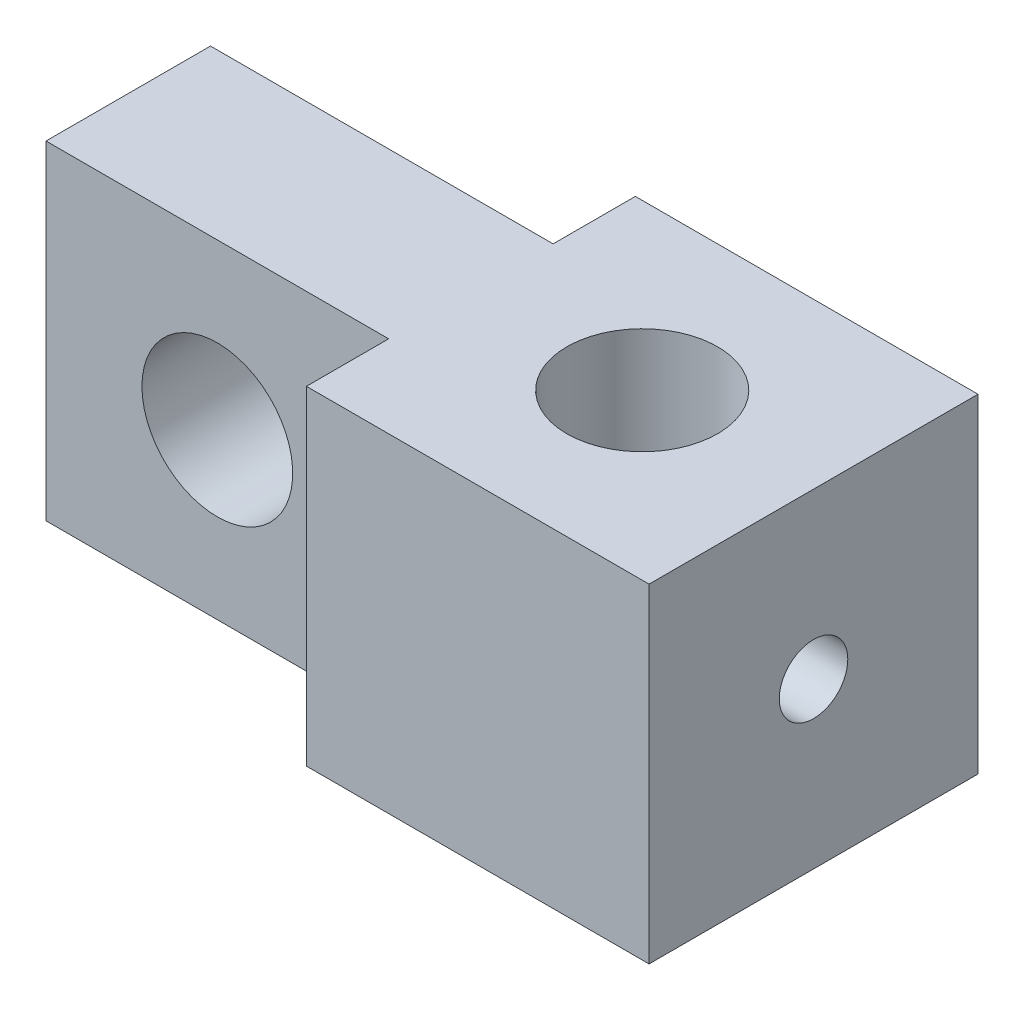
from build123d import *

# Parameters (mm, degrees)
SKIZZE1_W                       = 25
SKIZZE1_H                       = 12
SKIZZE1_R                       = 2.75
AUFSATZ_LINEAR_AUSTRAGEN1_DEPTH = 6
SKIZZE2_R                       = 2.75
SKIZZE2_W                       = 12.5
SKIZZE2_H                       = 3
SCHNITT_LINEAR_AUSTRAGEN1_DEPTH = 13
SCHNITT_LINEAR_AUSTRAGEN2_REACH = 27
SKIZZE3_R                       = 1.25


with BuildPart() as part:
    # Skizze1 → Aufsatz-Linear austragen1 (new body, symmetric)
    with BuildSketch(Plane.XY):
        Rectangle(SKIZZE1_W, SKIZZE1_H)
        with Locations((-6.25, 0)):
            Circle(SKIZZE1_R, mode=Mode.SUBTRACT)
    extrude(amount=AUFSATZ_LINEAR_AUSTRAGEN1_DEPTH, both=True)

    # Skizze2 → Schnitt-Linear austragen1 (cut, through all)
    with BuildSketch(Plane(origin=(0, 6, 0), x_dir=(1, 0, 0), z_dir=(0, 1, 0))):
        with Locations((6.25, 0)):
            Circle(SKIZZE2_R)
        with Locations((-6.25, 4.5)):
            Rectangle(SKIZZE2_W, SKIZZE2_H)
        with Locations((-6.25, -4.5)):
            Rectangle(SKIZZE2_W, SKIZZE2_H)
    extrude(amount=-SCHNITT_LINEAR_AUSTRAGEN1_DEPTH, mode=Mode.SUBTRACT)

    # Skizze3 → Schnitt-Linear austragen2 (cut, up to next)
    with BuildSketch(Plane(origin=(12.5, 0, 0), x_dir=(0, 0, -1), z_dir=(1, 0, 0)), mode=Mode.PRIVATE) as schnitt_linear_austragen2_sk1:
        Circle(SKIZZE3_R)
    schnitt_linear_austragen2_tool1 = extrude(schnitt_linear_austragen2_sk1.sketch, amount=-SCHNITT_LINEAR_AUSTRAGEN2_REACH, mode=Mode.PRIVATE) & part.part
    add(schnitt_linear_austragen2_tool1.solids().sort_by_distance((12.5, 0, 0))[0], mode=Mode.SUBTRACT)


solid = part.part
